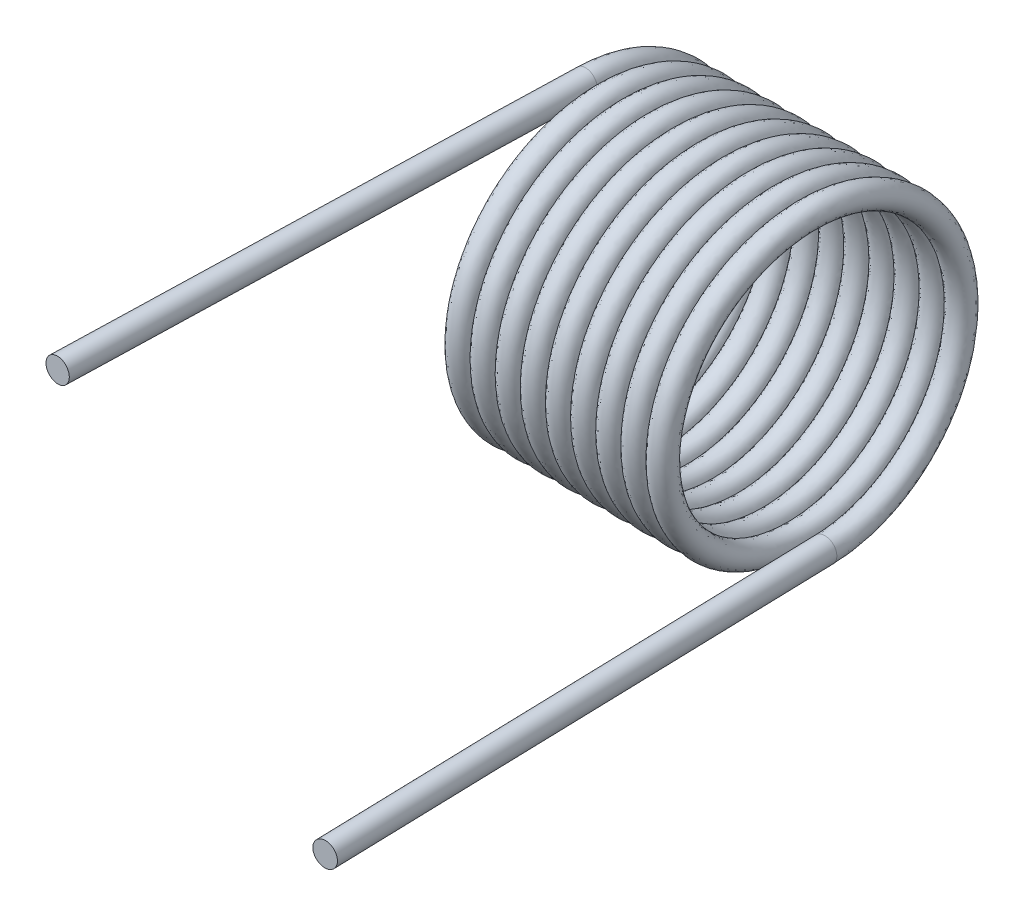
from build123d import *

# Parameters (mm, degrees)
SWEEP1_PITCH       = 0.5588
SWEEP1_HEIGHT      = 5.3086
SWEEP1_RADIUS      = 3.175
SWEEP1_START_ANGLE = -90
SKETCH2_R          = 0.2667
SKETCH3_R          = 0.2667
EXTRUDE1_DEPTH     = 11.43
SKETCH4_R          = 0.2667
EXTRUDE2_DEPTH     = 11.43


with BuildPart() as part:
    # Sweep1: sweep along a helix
    with BuildLine() as sweep1_path:
        add(Helix(SWEEP1_PITCH, SWEEP1_HEIGHT, SWEEP1_RADIUS, center=(0, 0, 0), direction=(1, 0, 0), lefthand=True, mode=Mode.PRIVATE).rotate(Axis((0, 0, 0), (1, 0, 0)), SWEEP1_START_ANGLE))
    # Sketch2 → Sweep1 (sweep)
    with BuildSketch(Plane(origin=(0, 3.175, 0), x_dir=(0.774449983, 0.632263097, 0.021693328), z_dir=(0.028000287, 0, -0.999607915))):
        Circle(SKETCH2_R)
    sweep(path=sweep1_path.line, is_frenet=True)

    # Sketch3 → Extrude1 (add)
    with BuildSketch(Plane(origin=(0, 0, 0), x_dir=(-0.774449983, -0.632263097, -0.021693328), z_dir=(-0.028000287, 0, 0.999607915))):
        with Locations((-2.007435334, -2.459843162)):
            Circle(SKETCH3_R)
    extrude(amount=EXTRUDE1_DEPTH)

    # Sketch4 → Extrude2 (add)
    with BuildSketch(Plane(origin=(0.004162028, 0, 0.148584044), x_dir=(0.817570581, -0.575372818, -0.02290119), z_dir=(0.028000287, 0, 0.999607915))):
        with Locations((6.166963886, 0.456421785)):
            Circle(SKETCH4_R)
    extrude(amount=EXTRUDE2_DEPTH)


solid = part.part
